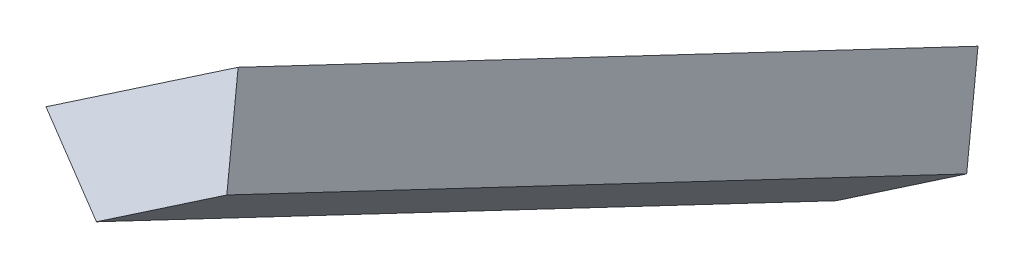
from build123d import *

# Parameters (mm, degrees)
BOSS_EXTRUDE2_DEPTH = 6


with BuildPart() as part:
    # Sketch2 → Boss-Extrude2 (new body)
    with BuildSketch(Plane(origin=(8.27759666, 23.107533757, 39.476724988), x_dir=(0.984018021, -0.089954406, -0.153677384), z_dir=(0.178068901, 0.497092732, 0.849229229))):
        Polygon((-19.321382447, 76.571333978), (-19.798732579, 76.241884663), (-20.179349115, 76.555476282), (-19.475807149, 77.041034791), align=None)
    extrude(amount=BOSS_EXTRUDE2_DEPTH)


solid = part.part
